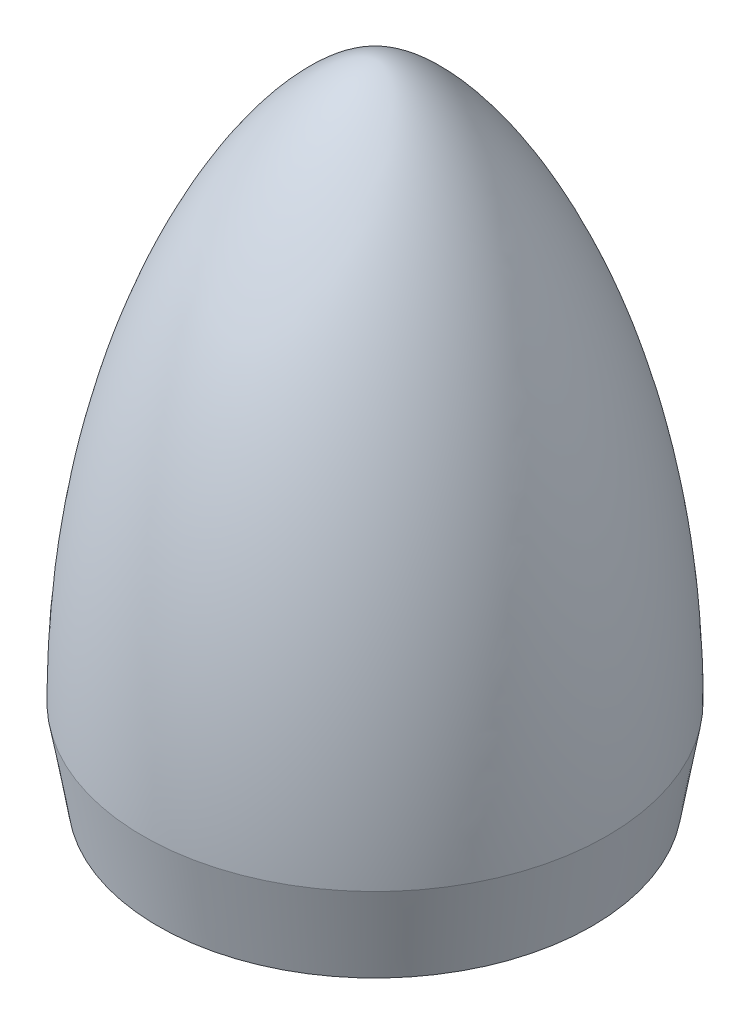
from build123d import *

# Parameters (mm, degrees)
THICKEN1_T1         = 1.2
BOSS_EXTRUDE8_REACH = 77.386
SKETCH7_W           = 21
SKETCH7_H           = 3.2
CUT_EXTRUDE1_DEPTH  = 2


with BuildPart() as body_1:
    # Surface-Revolve1: a surface, the sketch's curves turned about an axis
    with BuildLine(Plane.XY, mode=Mode.PRIVATE) as surface_revolve1_1_path:
        Line((25.375, 0), (27.125, 10))
        add(Edge.make_bspline(
            [(27.125, 10), (27.125, 50), (8.333333333, 75), (0, 75)],
            knots=[0, 0, 0, 0, 1, 1, 1, 1], degree=3))
    surface_revolve1_1 = Shell.revolve(surface_revolve1_1_path.wire(), 360, Axis((0, 75, 0), (0, -1, 0)))
    add(Solid.thicken(surface_revolve1_1, THICKEN1_T1))

    # Sketch4 → Boss-Extrude8 (add, up to next)
    with BuildSketch(Plane.XZ.offset(-10.103964032), mode=Mode.PRIVATE) as boss_extrude8_sk1:
        with BuildLine():
            Line((-25.905663661, 1), (25.905663661, 1))
            ThreePointArc((25.905663661, 1), (25.924957275, 0), (25.905663661, -1))
            Line((25.905663661, -1), (-25.905663661, -1))
            ThreePointArc((-25.905663661, -1), (-25.924957275, 0), (-25.905663661, 1))
        make_face()
    boss_extrude8_tool1 = extrude(boss_extrude8_sk1.sketch, amount=-BOSS_EXTRUDE8_REACH, mode=Mode.PRIVATE) - body_1.part
    add(boss_extrude8_tool1.solids().sort_by_distance((0, 10.103964, 0))[0])

    # Sketch7 → Cut-Extrude1 (cut)
    with BuildSketch(Plane.XY.offset(1)):
        with Locations((0, 20)):
            Rectangle(SKETCH7_W, SKETCH7_H)
        with Locations((0, 41)):
            Rectangle(SKETCH7_W, SKETCH7_H)
    extrude(amount=-CUT_EXTRUDE1_DEPTH, mode=Mode.SUBTRACT)


solid = body_1.part
